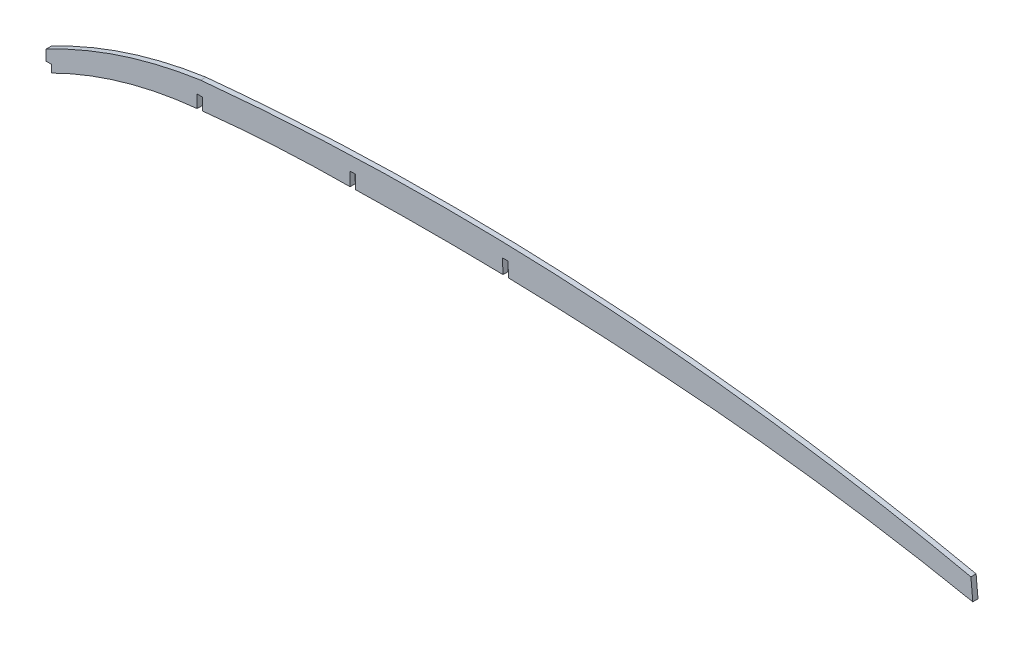
from build123d import *

# Parameters (mm, degrees)
BOSS_EXTRUDE1_DEPTH = 1.5875
SKETCH2_W           = 3.302
SKETCH2_H           = 6.35
SKETCH2_W_2         = 3.3782
SKETCH2_H_2         = 12.7
CUT_EXTRUDE1_DEPTH  = 583.351295045


with BuildPart() as part:
    # Sketch1 → Boss-Extrude1 (new, symmetric)
    with BuildSketch(Plane.XY):
        with BuildLine():
            Line((0, 98.649963947), (0, 85.942195343))
            ThreePointArc((0, 85.942195343), (44.883725347, 104.075489893), (92.3925, 113.364273632))
            ThreePointArc((92.3925, 113.364273632), (139.073495573, 117.280009783), (185.895946704, 118.731356536))
            ThreePointArc((185.895946704, 118.731356536), (279.546572247, 118.926979108), (373.101055052, 114.680017829))
            ThreePointArc((373.101055052, 114.680017829), (470.024153779, 105.277481614), (566.085246422, 89.316239979))
            Line((566.085246422, 89.316239979), (564.932089986, 101.967188211))
            add(Edge.make_bspline(
                [(564.932089986, 101.967188211), (526.305455218, 110.358765648), (487.405693808, 117.234573225), (438.439550099, 123.934433666), (428.624759847, 125.179975832), (408.998984047, 127.476532586), (399.18472115, 128.528085596), (369.737829992, 131.394153114), (350.101100844, 132.920187183), (291.174630327, 136.352842591), (251.868630305, 137.115735014), (173.213311456, 135.594221207), (133.863993721, 133.309891798), (94.492645692, 129.475822378)],
                knots=[0, 0, 0, 0, 0.25, 0.25, 0.3125, 0.3125, 0.375, 0.375, 0.5, 0.5, 0.75, 0.75, 1, 1, 1, 1], degree=3))
            ThreePointArc((94.492645692, 129.475822378), (45.925545315, 118.111564298), (0, 98.649963947))
        make_face()
    extrude(amount=BOSS_EXTRUDE1_DEPTH, both=True)

    # Sketch2 → Cut-Extrude1 (cut, through all)
    with BuildSketch(Plane.XY.offset(1.5875)):
        with Locations((1.651, 89.117195343)):
            Rectangle(SKETCH2_W, SKETCH2_H)
        with Locations((93.98, 114.711123803)):
            Rectangle(SKETCH2_W_2, SKETCH2_H_2)
        Polygon((185.566099292, 126.933217537), (188.943559255, 127.003924269), (189.209374036, 114.306706365), (185.831914074, 114.235999633), align=None)
        Polygon((278.780272456, 127.574359039), (282.155347854, 127.719621905), (282.701448855, 115.031368531), (279.326373458, 114.886105664), align=None)
    extrude(amount=-CUT_EXTRUDE1_DEPTH, mode=Mode.SUBTRACT)


solid = part.part
